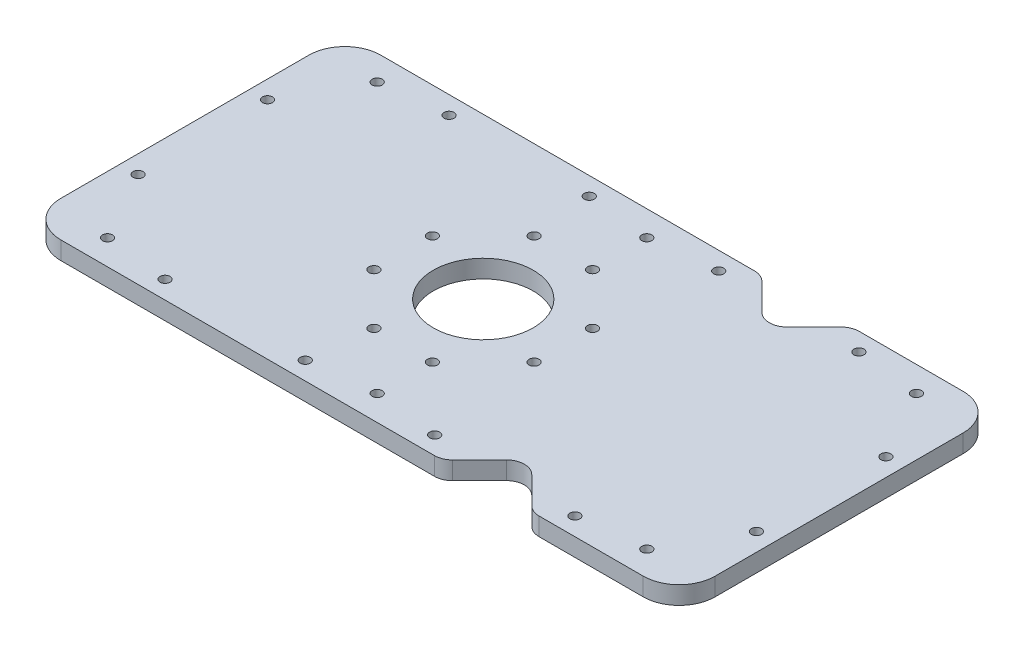
from build123d import *

# Parameters (mm, degrees)
SKETCH1_R           = 13.9
SKETCH1_R_2         = 1.4
BOSS_EXTRUDE1_DEPTH = 5


with BuildPart() as part:
    # Sketch1 → Boss-Extrude1 (new body)
    with BuildSketch(Plane(origin=(0, 0, 0), x_dir=(1, 0, 0), z_dir=(0, 1, 0))):
        with BuildLine():
            Line((26.464466094, -43.035533906), (33.964466094, -35.535533906))
            ThreePointArc((33.964466094, -35.535533906), (37.5, -34.071067812), (41.035533906, -35.535533906))
            Line((41.035533906, -35.535533906), (48.535533906, -43.035533906))
            ThreePointArc((48.535533906, -43.035533906), (50.15765065, -44.119397663), (52.071067812, -44.5))
            Line((52.071067812, -44.5), (81, -44.5))
            ThreePointArc((81, -44.5), (88.071067812, -41.571067812), (91, -34.5))
            Line((91, -34.5), (91, 34.5))
            ThreePointArc((91, 34.5), (88.071067812, 41.571067812), (81, 44.5))
            Line((81, 44.5), (52.071067812, 44.5))
            ThreePointArc((52.071067812, 44.5), (50.15765065, 44.119397663), (48.535533906, 43.035533906))
            Line((48.535533906, 43.035533906), (41.035533906, 35.535533906))
            ThreePointArc((41.035533906, 35.535533906), (37.5, 34.071067812), (33.964466094, 35.535533906))
            Line((33.964466094, 35.535533906), (26.464466094, 43.035533906))
            ThreePointArc((26.464466094, 43.035533906), (24.84234935, 44.119397663), (22.928932188, 44.5))
            Line((22.928932188, 44.5), (-81, 44.5))
            ThreePointArc((-81, 44.5), (-88.071067812, 41.571067812), (-91, 34.5))
            Line((-91, 34.5), (-91, -34.5))
            ThreePointArc((-91, -34.5), (-88.071067812, -41.571067812), (-81, -44.5))
            Line((-81, -44.5), (22.928932188, -44.5))
            ThreePointArc((22.928932188, -44.5), (24.84234935, -44.119397663), (26.464466094, -43.035533906))
        make_face()
        with Locations((-8, 0)):
            Circle(SKETCH1_R, mode=Mode.SUBTRACT)
        with Locations((-30.273863607, 8.131727984)):
            Circle(SKETCH1_R_2, mode=Mode.SUBTRACT)
        with Locations((-16.131727984, 22.273863607)):
            Circle(SKETCH1_R_2, mode=Mode.SUBTRACT)
        with Locations((0.131727984, 22.273863607)):
            Circle(SKETCH1_R_2, mode=Mode.SUBTRACT)
        with Locations((14.273863607, 8.131727984)):
            Circle(SKETCH1_R_2, mode=Mode.SUBTRACT)
        with Locations((14.273863607, -8.131727984)):
            Circle(SKETCH1_R_2, mode=Mode.SUBTRACT)
        with Locations((0.131727984, -22.273863607)):
            Circle(SKETCH1_R_2, mode=Mode.SUBTRACT)
        with Locations((-16.131727984, -22.273863607)):
            Circle(SKETCH1_R_2, mode=Mode.SUBTRACT)
        with Locations((-30.273863607, -8.131727984)):
            Circle(SKETCH1_R_2, mode=Mode.SUBTRACT)
        with Locations((-75, -37.5)):
            Circle(SKETCH1_R_2, mode=Mode.SUBTRACT)
        with Locations((-57, -39.5)):
            Circle(SKETCH1_R_2, mode=Mode.SUBTRACT)
        with Locations((-18, -39.5)):
            Circle(SKETCH1_R_2, mode=Mode.SUBTRACT)
        with Locations((0, -37.5)):
            Circle(SKETCH1_R_2, mode=Mode.SUBTRACT)
        with Locations((18, -39.5)):
            Circle(SKETCH1_R_2, mode=Mode.SUBTRACT)
        with Locations((57, -39.5)):
            Circle(SKETCH1_R_2, mode=Mode.SUBTRACT)
        with Locations((75, -37.5)):
            Circle(SKETCH1_R_2, mode=Mode.SUBTRACT)
        with Locations((86, -18)):
            Circle(SKETCH1_R_2, mode=Mode.SUBTRACT)
        with Locations((86, 18)):
            Circle(SKETCH1_R_2, mode=Mode.SUBTRACT)
        with Locations((75, 37.5)):
            Circle(SKETCH1_R_2, mode=Mode.SUBTRACT)
        with Locations((57, 39.5)):
            Circle(SKETCH1_R_2, mode=Mode.SUBTRACT)
        with Locations((18, 39.5)):
            Circle(SKETCH1_R_2, mode=Mode.SUBTRACT)
        with Locations((0, 37.5)):
            Circle(SKETCH1_R_2, mode=Mode.SUBTRACT)
        with Locations((-18, 39.5)):
            Circle(SKETCH1_R_2, mode=Mode.SUBTRACT)
        with Locations((-57, 39.5)):
            Circle(SKETCH1_R_2, mode=Mode.SUBTRACT)
        with Locations((-75, 37.5)):
            Circle(SKETCH1_R_2, mode=Mode.SUBTRACT)
        with Locations((-86, 18)):
            Circle(SKETCH1_R_2, mode=Mode.SUBTRACT)
        with Locations((-86, -18)):
            Circle(SKETCH1_R_2, mode=Mode.SUBTRACT)
    extrude(amount=BOSS_EXTRUDE1_DEPTH)


solid = part.part
